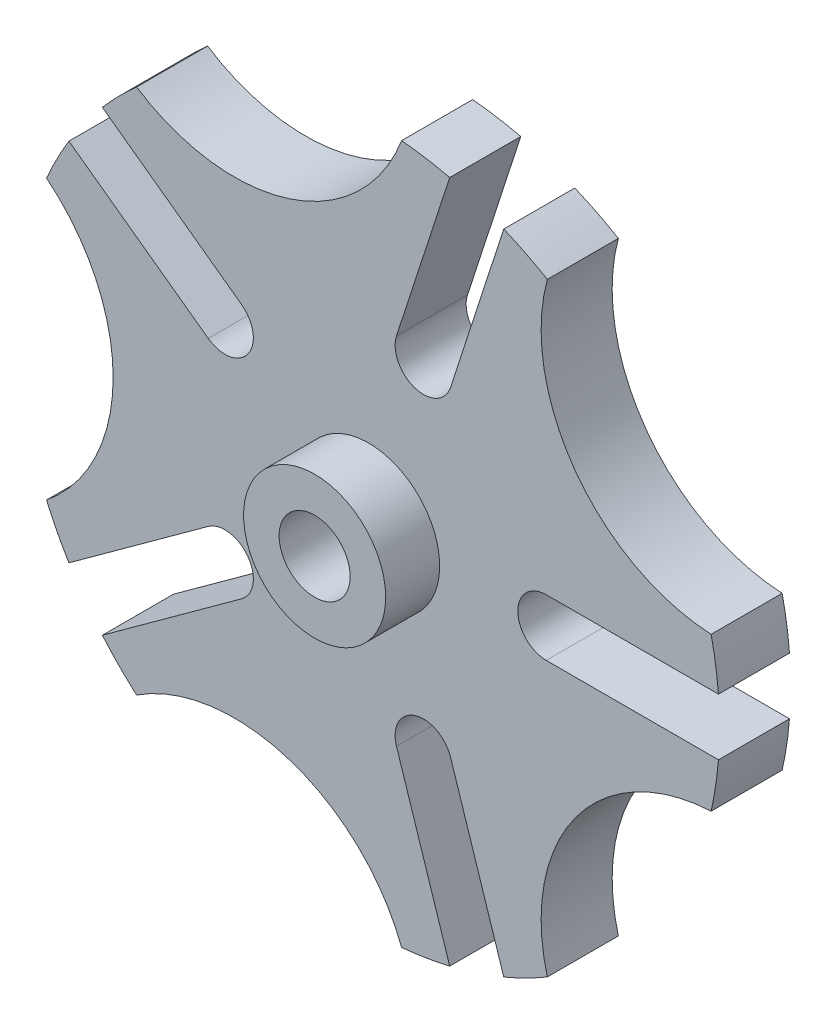
from build123d import *

# Parameters (mm, degrees)
BOSS_EXTRUDE1_DEPTH         = 6.35
CIRPATTERN1_COUNT           = 5
SKETCH3_R                   = 6.35
BOSS_EXTRUDE2_DEPTH         = 4.826
F_1_4_0_25_DIAMETER_HOLE1_D = 6.35


with BuildPart() as part:
    # Sketch2 → Boss-Extrude1 (new body)
    with BuildSketch(Plane.XY):
        with BuildLine():
            Line((4.12074162, 12.682338645), (0, 0))
            Line((0, 0), (13.335, 0))
            ThreePointArc((13.335, 0), (14.078948776, 1.796051224), (15.875, 2.54))
            Line((15.875, 2.54), (31.265996882, 2.54))
            ThreePointArc((31.265996882, 2.54), (31.014248813, 4.704309891), (30.612864998, 6.845922701))
            ThreePointArc((30.612864998, 6.845922701), (18.47357946, 13.421841122), (15.970754926, 26.999058282))
            ThreePointArc((15.970754926, 26.999058282), (14.057994528, 28.042591729), (12.077407934, 28.950826907))
            Line((12.077407934, 28.950826907), (7.321328337, 14.31311903))
            ThreePointArc((7.321328337, 14.31311903), (6.058780655, 12.834865625), (4.12074162, 12.682338645))
        make_face()
    boss_extrude1 = extrude(amount=BOSS_EXTRUDE1_DEPTH)

    # CirPattern1: Boss-Extrude1 ×5 about axis
    cirpattern1_axis = Axis((0, 0, 0), (0, 0, 1))
    for i in range(1, CIRPATTERN1_COUNT):
        add(boss_extrude1.rotate(cirpattern1_axis, i * 360 / CIRPATTERN1_COUNT))

    # Sketch3 → Boss-Extrude2 (add)
    with BuildSketch(Plane.XY.offset(6.35)):
        Circle(SKETCH3_R)
    extrude(amount=BOSS_EXTRUDE2_DEPTH)

    # 1/4 (0.25) Diameter Hole1 (through all)
    with Locations(Plane.XY.offset(11.176)):
        with Locations((0, 0)):
            Hole(F_1_4_0_25_DIAMETER_HOLE1_D / 2)


solid = part.part
